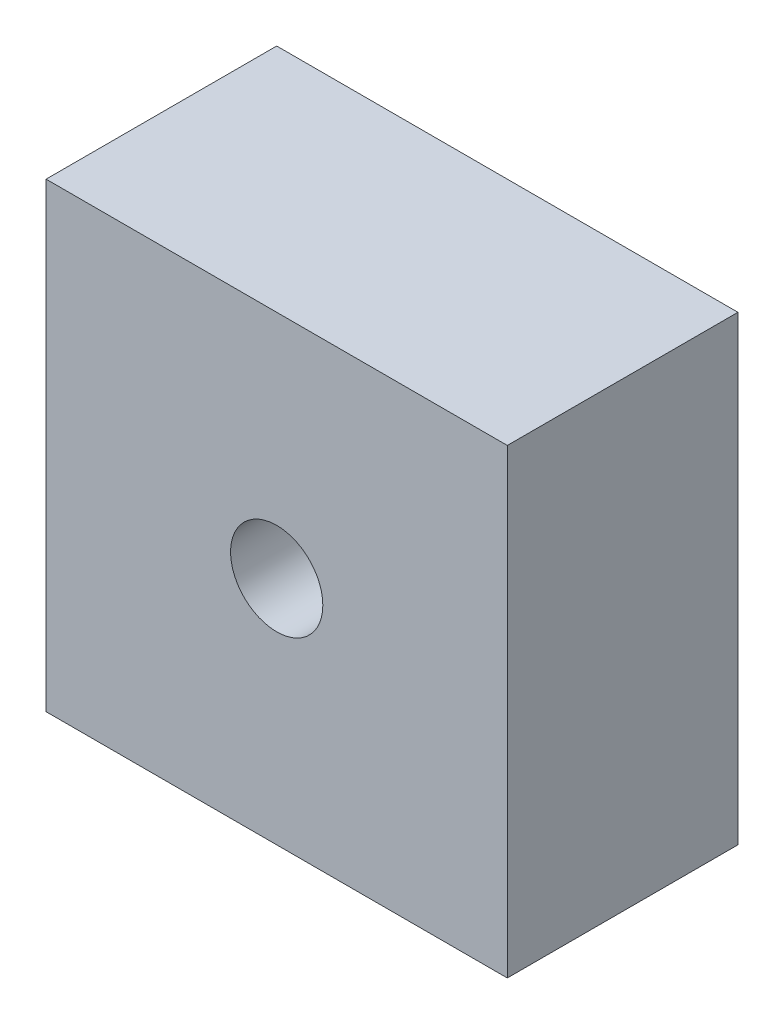
from build123d import *

# Parameters (mm, degrees)
SKETCH1_W           = 127
SKETCH1_H           = 127
BOSS_EXTRUDE1_DEPTH = 63.5
SKETCH2_R           = 12.7
CUT_EXTRUDE1_DEPTH  = 63.5


with BuildPart() as part:
    # Sketch1 → Boss-Extrude1 (new body)
    with BuildSketch(Plane.XY):
        Rectangle(SKETCH1_W, SKETCH1_H)
    extrude(amount=-BOSS_EXTRUDE1_DEPTH)

    # Sketch2 → Cut-Extrude1 (cut)
    with BuildSketch(Plane.XY):
        Circle(SKETCH2_R)
    extrude(amount=-CUT_EXTRUDE1_DEPTH, mode=Mode.SUBTRACT)


solid = part.part
